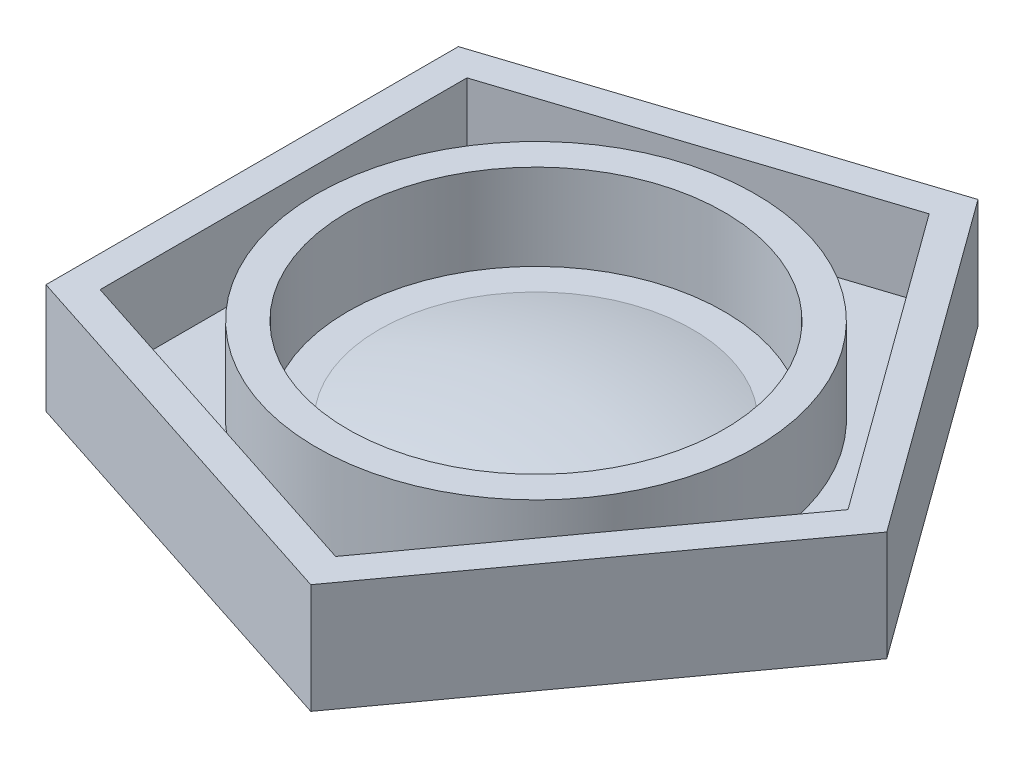
from build123d import *

# Parameters (mm, degrees)
BOSS_EXTRUDE1_DEPTH = 2.54
BOSS_EXTRUDE2_DEPTH = 6.35


with BuildPart() as part:
    # Sketch1 → Revolve1 (revolve)
    with BuildSketch(Plane.XY):
        with BuildLine():
            Line((0, -13.880770422), (0, -18.033881925))
            Line((0, -18.033881925), (17.78, -18.033881925))
            Line((17.78, -18.033881925), (17.78, -8.528719197))
            Line((17.78, -8.528719197), (15.24, -8.528719197))
            Line((15.24, -8.528719197), (15.24, -15.493881925))
            Line((15.24, -15.493881925), (12.7, -15.493881925))
            ThreePointArc((12.7, -15.493881925), (6.401018058, -14.285661851), (0, -13.880770422))
        make_face()
    revolve(axis=Axis((0, -13.880770422, 0), (0, -1, 0)))

    # Sketch2 → Boss-Extrude1 (add)
    with BuildSketch(Plane.XZ.offset(18.033881925)):
        Polygon((28.413494599, 0), (8.780252701, 27.022839189), (-22.987, 16.701033091), (-22.987, -16.701033091), (8.780252701, -27.022839189), align=None)
    extrude(amount=-BOSS_EXTRUDE1_DEPTH)

    # Sketch3 → Boss-Extrude2 (add)
    with BuildSketch(Plane(origin=(0, -15.493881925, 0), x_dir=(1, 0, 0), z_dir=(0, 1, 0))):
        Polygon((28.413494599, 0), (8.780252701, 27.022839189), (-22.987, 16.701033091), (-22.987, -16.701033091), (8.780252701, -27.022839189), align=None)
        Polygon((25.273881936, 0), (7.810059032, 24.036890107), (-20.447, 14.85561507), (-20.447, -14.85561507), (7.810059032, -24.036890107), align=None, mode=Mode.SUBTRACT)
    extrude(amount=BOSS_EXTRUDE2_DEPTH)


solid = part.part
